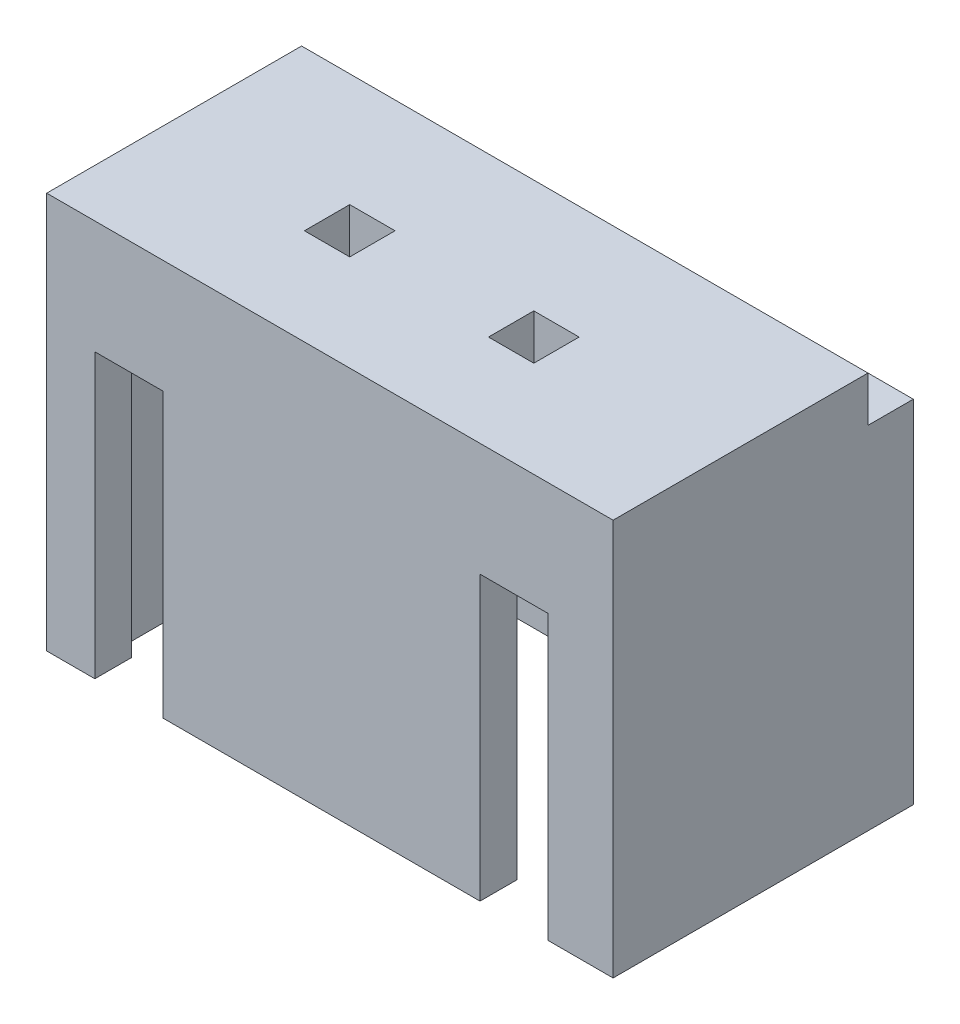
from build123d import *

# Parameters (mm, degrees)
SKETCH1_W           = 10
SKETCH1_H           = 5.3
BOSS_EXTRUDE1_DEPTH = 7
SKETCH3_W           = 8.8
SKETCH3_H           = 4
CUT_EXTRUDE1_DEPTH  = 5
SKETCH4_W           = 1.2
SKETCH4_H           = 5
CUT_EXTRUDE2_DEPTH  = 4
SKETCH5_W           = 10
SKETCH5_H           = 0.8
CUT_EXTRUDE3_DEPTH  = 0.8
SKETCH6_W           = 0.8
SKETCH6_H           = 0.8
CUT_EXTRUDE4_DEPTH  = 10
SKETCH7_W           = 8.8
SKETCH7_H           = 1
CUT_EXTRUDE5_DEPTH  = 0.3


with BuildPart() as part:
    # Sketch1 → Boss-Extrude1 (new body)
    with BuildSketch(Plane(origin=(0, 0, 0), x_dir=(1, 0, 0), z_dir=(0, 1, 0))):
        Rectangle(SKETCH1_W, SKETCH1_H)
    extrude(amount=BOSS_EXTRUDE1_DEPTH)

    # Sketch3 → Cut-Extrude1 (cut)
    with BuildSketch(Plane.XZ):
        Rectangle(SKETCH3_W, SKETCH3_H)
    extrude(amount=-CUT_EXTRUDE1_DEPTH, mode=Mode.SUBTRACT)

    # Sketch4 → Cut-Extrude2 (cut)
    with BuildSketch(Plane.XY.offset(2.65)):
        with Locations((-3.55, 2.5)):
            Rectangle(SKETCH4_W, SKETCH4_H)
        with Locations((3.25, 2.5)):
            Rectangle(SKETCH4_W, SKETCH4_H)
    extrude(amount=-CUT_EXTRUDE2_DEPTH, mode=Mode.SUBTRACT)

    # Sketch5 → Cut-Extrude3 (cut)
    with BuildSketch(Plane(origin=(0, 7, 0), x_dir=(1, 0, 0), z_dir=(0, 1, 0))):
        with Locations((0, 2.25)):
            Rectangle(SKETCH5_W, SKETCH5_H)
    extrude(amount=-CUT_EXTRUDE3_DEPTH, mode=Mode.SUBTRACT)

    # Sketch6 → Cut-Extrude4 (cut)
    with BuildSketch(Plane(origin=(0, 7, 0), x_dir=(1, 0, 0), z_dir=(0, 1, 0))):
        with Locations((1.5, -0.55)):
            Rectangle(SKETCH6_W, SKETCH6_H)
        with Locations((-1.75, -0.55)):
            Rectangle(SKETCH6_W, SKETCH6_H)
    extrude(amount=-CUT_EXTRUDE4_DEPTH, mode=Mode.SUBTRACT)

    # Sketch7 → Cut-Extrude5 (cut)
    with BuildSketch(Plane.XZ.offset(-5)):
        with Locations((0, -1.5)):
            Rectangle(SKETCH7_W, SKETCH7_H)
    extrude(amount=-CUT_EXTRUDE5_DEPTH, mode=Mode.SUBTRACT)


solid = part.part
